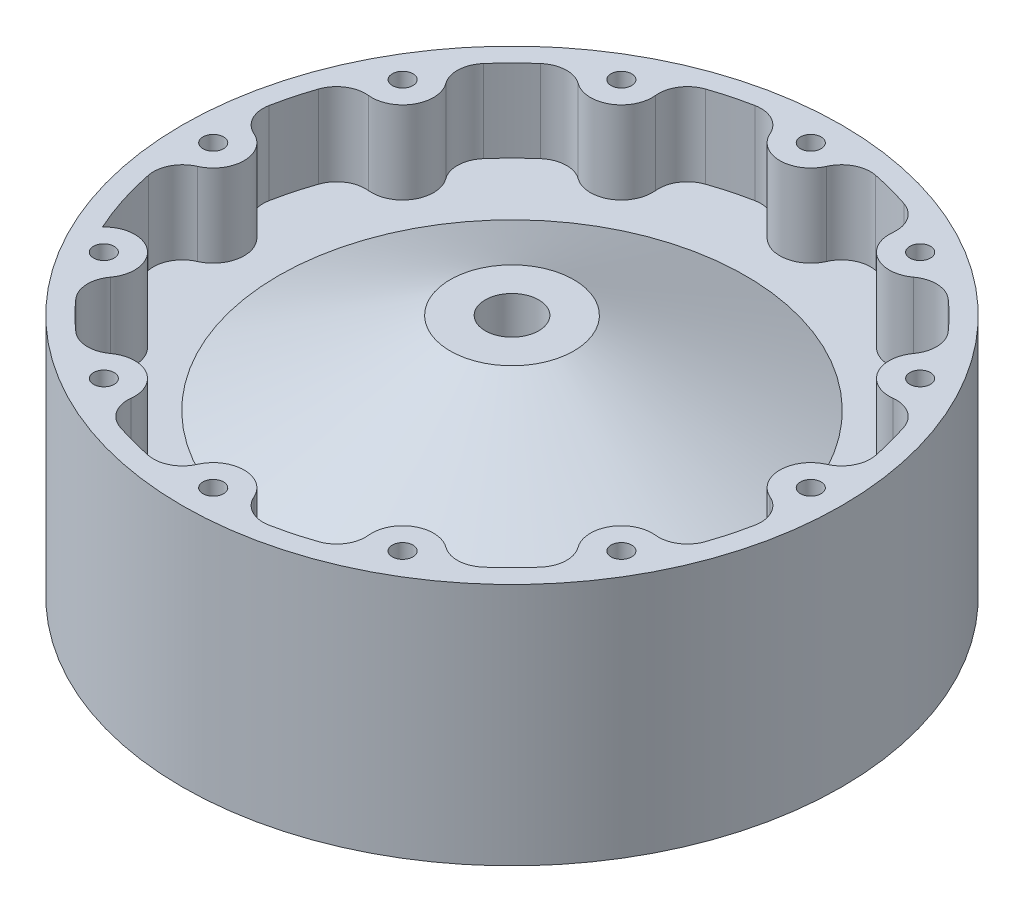
from build123d import *

# Parameters (mm, degrees)
BOSS_EXTRUDE3_START   = -25.4
SKETCH15_R            = 9.525
BOSS_EXTRUDE3_DEPTH   = 25.4
SKETCH17_R            = 3.175
CUT_EXTRUDE5_DEPTH    = 25.4
CIRPATTERN5_COUNT     = 12
FILLET2_R             = 8.89
BODY_MOVE_COPY1_ANGLE = 90


with BuildPart() as part:
    # Sketch1 → Revolve1 (revolve)
    with BuildSketch(Plane(origin=(0, 0, 0), x_dir=(1, 0, 0), z_dir=(0, 1, 0))):
        with BuildLine():
            add(Edge.make_bspline(
                [(95.25, 0), (95.25, 56.03262193), (8.255, 60.888782497)],
                knots=[3.141592654, 3.141592654, 3.141592654, 4.625613452, 4.625613452, 4.625613452], degree=2, weights=[1, 0.73711148, 1]))
            Line((95.25, 0), (101.6, 0))
            Line((101.6, 0), (101.6, 61.11875))
            Line((101.6, 61.11875), (101.6, 75.08875))
            Line((101.6, 75.08875), (95.25, 75.08875))
            Line((95.25, 75.08875), (95.25, 49.68875))
            Line((95.25, 49.68875), (71.966666667, 49.68875))
            Line((71.966666667, 49.68875), (19.05, 75.08875))
            Line((19.05, 75.08875), (8.255, 75.08875))
            Line((8.255, 75.08875), (8.255, 60.888782497))
        make_face()
    revolve(axis=Axis((0, 0, 0), (0, 0, -1)))

    # Sketch15 → Boss-Extrude3 (add)
    with BuildSketch(Plane(origin=(0, 0, -75.08875), x_dir=(-1, 0, 0), z_dir=(0, 0, -1)).offset(BOSS_EXTRUDE3_START)):
        with Locations((0, -92.075)):
            Circle(SKETCH15_R)
    boss_extrude3 = extrude(amount=BOSS_EXTRUDE3_DEPTH)

    # Sketch17 → Cut-Extrude5 (cut)
    with BuildSketch(Plane(origin=(0, 0, -75.08875), x_dir=(-1, 0, 0), z_dir=(0, 0, -1))):
        with Locations((0, -92.075)):
            Circle(SKETCH17_R)
    cut_extrude5 = extrude(amount=-CUT_EXTRUDE5_DEPTH, mode=Mode.SUBTRACT)

    # CirPattern5: Boss-Extrude3, Cut-Extrude5 ×12 about axis
    cirpattern5_axis = Axis((0, 0, 0), (0, 0, 1))
    for i in range(1, CIRPATTERN5_COUNT):
        add(boss_extrude3.rotate(cirpattern5_axis, i * 360 / CIRPATTERN5_COUNT))
        add(cut_extrude5.rotate(cirpattern5_axis, i * 360 / CIRPATTERN5_COUNT), mode=Mode.SUBTRACT)

    # Fillet2
    fillet2_edges = [part.edges().sort_by_distance(p)[0] for p in [
        (-55.307019159, 77.54802468, -62.38875),
        (-39.505049806, 86.671295939, -62.38875),
        (-77.54802468, 55.307019159, -62.38875),
        (-94.812068966, -9.12327126, -62.38875),
        (-94.812068966, 9.12327126, -62.38875),
        (-77.54802468, -55.307019159, -62.38875),
        (-86.671295939, -39.505049806, -62.38875),
        (-39.505049806, -86.671295939, -62.38875),
        (-55.307019159, -77.54802468, -62.38875),
        (9.12327126, -94.812068966, -62.38875),
        (-9.12327126, -94.812068966, -62.38875),
        (55.307019159, -77.54802468, -62.38875),
        (39.505049806, -86.671295939, -62.38875),
        (86.671295939, -39.505049806, -62.38875),
        (77.54802468, -55.307019159, -62.38875),
        (94.812068966, 9.12327126, -62.38875),
        (94.812068966, -9.12327126, -62.38875),
        (77.54802468, 55.307019159, -62.38875),
        (86.671295939, 39.505049806, -62.38875),
        (39.505049806, 86.671295939, -62.38875),
        (55.307019159, 77.54802468, -62.38875),
        (-9.12327126, 94.812068966, -62.38875),
        (9.12327126, 94.812068966, -62.38875),
    ]]
    fillet(fillet2_edges, radius=FILLET2_R)


with BuildPart() as part_1:
    # Body-Move/Copy1: moved
    add(part.part.rotate(Axis((0, 0, -37.544375), (1, 0, 0)), BODY_MOVE_COPY1_ANGLE))


solid = part_1.part
